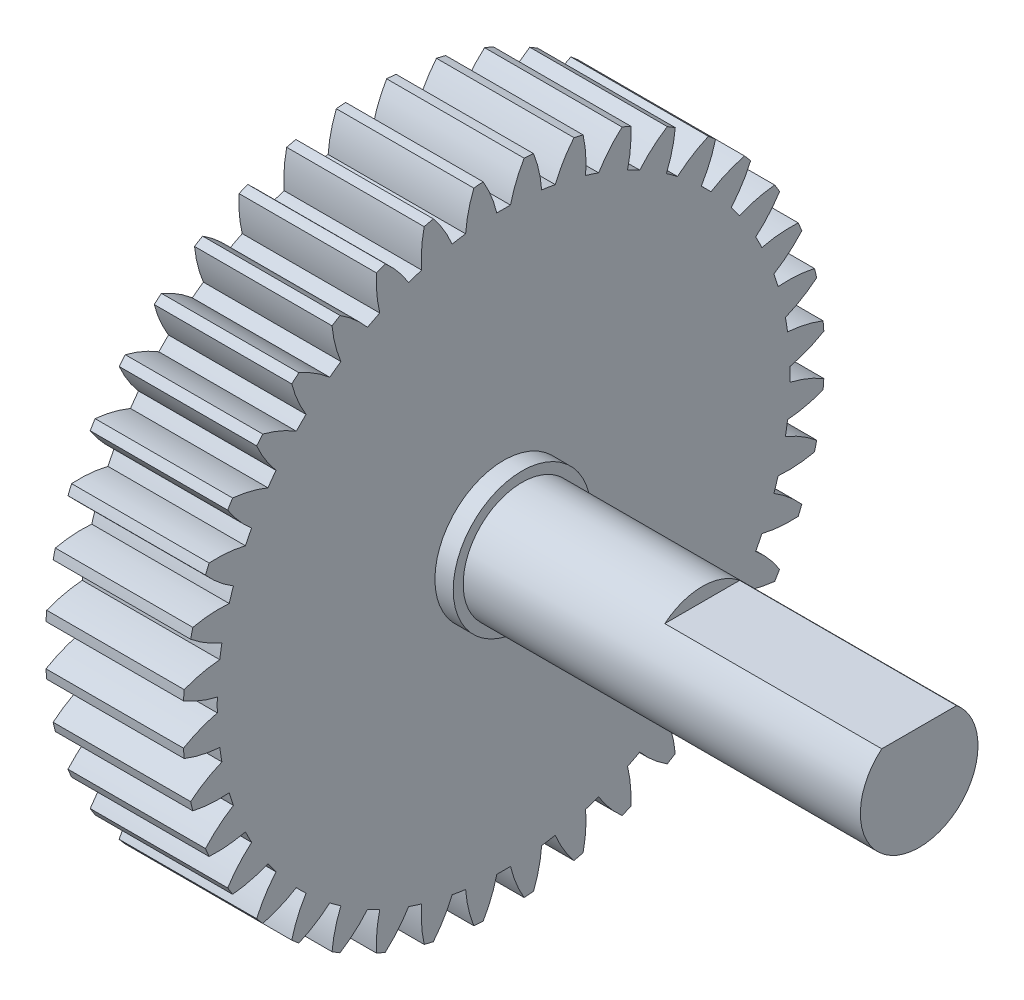
from build123d import *

# Parameters (mm, degrees)
BASPROSKE_W              = 9
BASPROSKE_H              = 21
TOOTHCUT_DEPTH           = 32.032241298
TEETHCUTS_COUNT          = 40
TEETHCUTS_ANGLE          = 351
BORSKE_R                 = 2
BORE_DEPTH               = 50.0000508
BOSS_EXTRUDE1_DEPTH      = 27.2
BOSS_EXTRUDE1_DEPTH_BACK = 9
BOSS_EXTRUDE2_DEPTH      = 13
BOSS_EXTRUDE2_DEPTH_BACK = 9
SKETCH1_4_R              = 4.5
SKETCH1_4_R_2            = 3.85
BOSS_EXTRUDE3_DEPTH      = 1.2


with BuildPart() as part:
    # BasProSke → Base-Revolve (revolve)
    with BuildSketch(Plane(origin=(0, 0, 0), x_dir=(1, 0, 0), z_dir=(0, 1, 0)), mode=Mode.PRIVATE) as base_revolve_sk:
        with Locations((4.5, 10.5)):
            Rectangle(BASPROSKE_W, BASPROSKE_H)
    revolve(base_revolve_sk.sketch.rotate(Axis((-10, 0, 0), (1, 0, 0)), 180), axis=Axis((-10, 0, 0), (1, 0, 0)))

    # TooCutSke → ToothCut (cut, through all)
    with BuildSketch(Plane(origin=(0, 0, 0), x_dir=(0, 0, -1), z_dir=(1, 0, 0))):
        with BuildLine():
            ThreePointArc((0.448673268, 18.74363074), (0, 18.749), (-0.448673268, 18.74363074))
            ThreePointArc((-0.448673268, 18.74363074), (-0.816786816, 19.89705013), (-1.354745081, 20.981708961))
            ThreePointArc((-1.354745081, 20.981708961), (0, 21.0254), (1.354745081, 20.981708961))
            ThreePointArc((1.354745081, 20.981708961), (0.816786816, 19.89705013), (0.448673268, 18.74363074))
        make_face()
    toothcut = extrude(amount=TOOTHCUT_DEPTH, mode=Mode.SUBTRACT)

    # TeethCuts: ToothCut ×40 about axis
    teethcuts_axis = Axis((-10, 0, 0), (1, 0, 0))
    for i in range(1, TEETHCUTS_COUNT):
        add(toothcut.rotate(teethcuts_axis, i * TEETHCUTS_ANGLE / (TEETHCUTS_COUNT - 1)), mode=Mode.SUBTRACT)

    # BorSke → Bore (cut, symmetric)
    with BuildSketch(Plane(origin=(0, 0, 0), x_dir=(0, 0, -1), z_dir=(1, 0, 0))):
        with Locations(Location((0, 0, 0), (0, 0, 180))):
            Circle(BORSKE_R)
    extrude(amount=BORE_DEPTH, both=True, mode=Mode.SUBTRACT)

    # Sketch1 → Boss-Extrude1 (add, two sides)
    with BuildSketch(Plane(origin=(9, 0, 0), x_dir=(0, 0, -1), z_dir=(1, 0, 0))) as boss_extrude1_sk:
        with BuildLine():
            Line((2.45, 2.969848481), (-2.45, 2.969848481))
            ThreePointArc((-2.45, 2.969848481), (-1.641645516, -3.48245603), (3.85, 0))
            ThreePointArc((3.85, 0), (3.48245603, 1.641645516), (2.45, 2.969848481))
        make_face()
    extrude(amount=BOSS_EXTRUDE1_DEPTH)
    extrude(boss_extrude1_sk.sketch, amount=-BOSS_EXTRUDE1_DEPTH_BACK)

    # Sketch1_3 → Boss-Extrude2 (add, two sides)
    with BuildSketch(Plane(origin=(9, 0, 0), x_dir=(0, 0, -1), z_dir=(1, 0, 0))) as boss_extrude2_sk:
        with BuildLine():
            ThreePointArc((2.45, 2.969848481), (0, 3.85), (-2.45, 2.969848481))
            Line((-2.45, 2.969848481), (2.45, 2.969848481))
        make_face()
        with BuildLine():
            Line((2.45, 2.969848481), (-2.45, 2.969848481))
            ThreePointArc((-2.45, 2.969848481), (-1.641645516, -3.48245603), (3.85, 0))
            ThreePointArc((3.85, 0), (3.48245603, 1.641645516), (2.45, 2.969848481))
        make_face()
    extrude(amount=BOSS_EXTRUDE2_DEPTH)
    extrude(boss_extrude2_sk.sketch, amount=-BOSS_EXTRUDE2_DEPTH_BACK)

    # Sketch1_4 → Boss-Extrude3 (add)
    with BuildSketch(Plane(origin=(9, 0, 0), x_dir=(0, 0, -1), z_dir=(1, 0, 0))):
        with Locations(Location((0, 0, 0), (0, 0, 180))):
            Circle(SKETCH1_4_R)
        Circle(SKETCH1_4_R_2, mode=Mode.SUBTRACT)
    extrude(amount=BOSS_EXTRUDE3_DEPTH)


solid = part.part
